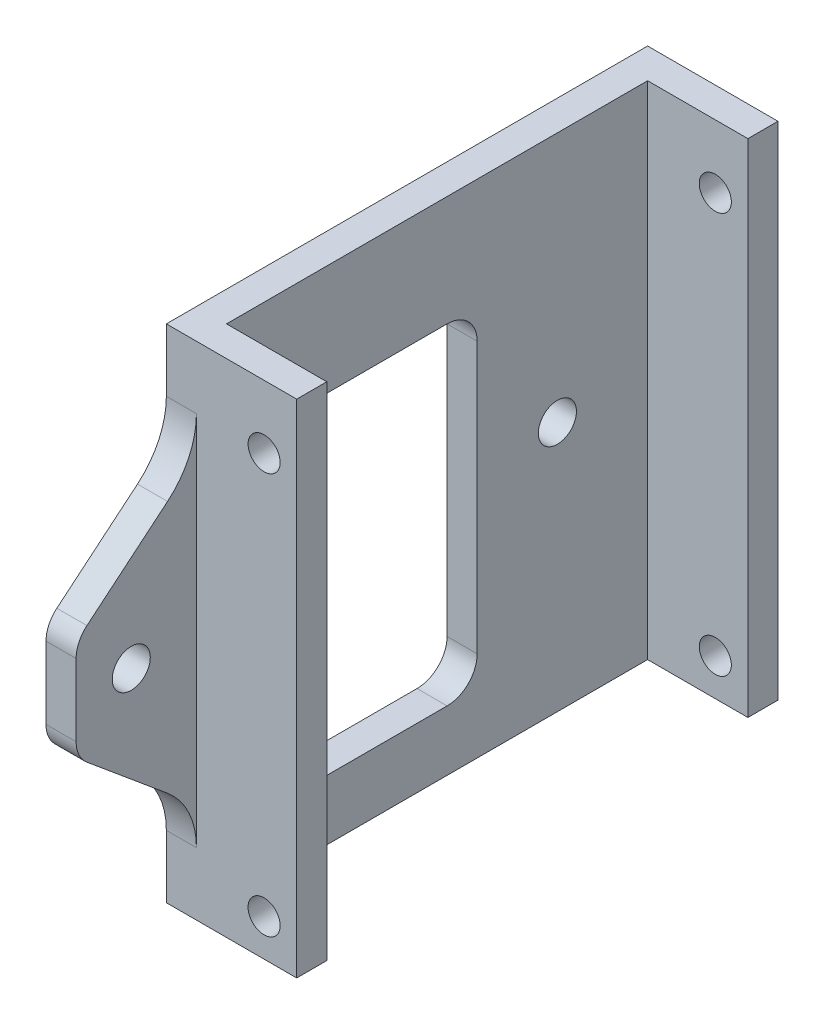
from build123d import *

# Parameters (mm, degrees)
BOSS_EXTRUDE1_DEPTH   = 50
SKETCH3_R             = 1.6
CUT_EXTRUDE1_DEPTH    = 49
SKETCH4_W             = 23.4
SKETCH4_H             = 33
CUT_EXTRUDE2_DEPTH    = 4
FILLET1_R             = 3
FILLET2_R             = 3
F_6_CLEARANCE_HOLE1_D = 3.7973


with BuildPart() as part:
    # Sketch1 → Boss-Extrude1 (new body)
    with BuildSketch(Plane(origin=(0, 0, 0), x_dir=(1, 0, 0), z_dir=(0, 1, 0))):
        Polygon((0, 0), (0, 48), (3, 48), (13, 48), (13, 45), (3, 45), (3, 3), (13, 3), (13, 0), (3, 0), (3, -12), (0, -12), align=None)
    extrude(amount=BOSS_EXTRUDE1_DEPTH)

    # Sketch3 → Cut-Extrude1 (cut, through all)
    with BuildSketch(Plane.XY):
        with Locations((9.75, 43.7)):
            Circle(SKETCH3_R)
        with Locations((9.75, 3.7)):
            Circle(SKETCH3_R)
    extrude(amount=-CUT_EXTRUDE1_DEPTH, mode=Mode.SUBTRACT)

    # Sketch4 → Cut-Extrude2 (cut, through all)
    with BuildSketch(Plane(origin=(3, 0, 0), x_dir=(0, 0, -1), z_dir=(1, 0, 0))):
        with BuildLine():
            Line((0, 50), (-12, 50))
            Line((-12, 50), (-12, 30))
            Line((-12, 30), (-2.878524803, 37.601229331))
            ThreePointArc((-2.878524803, 37.601229331), (-0.75528463, 40.353756398), (0, 43.746999568))
            Line((0, 43.746999568), (0, 50))
        make_face()
        with BuildLine():
            Line((0, 0), (0, 6.253000432))
            ThreePointArc((0, 6.253000432), (-0.75528463, 9.646243602), (-2.878524803, 12.398770669))
            Line((-2.878524803, 12.398770669), (-12, 20))
            Line((-12, 20), (-12, 0))
            Line((-12, 0), (0, 0))
        make_face()
        with Locations((16.3, 22.5)):
            Rectangle(SKETCH4_W, SKETCH4_H)
    extrude(amount=-CUT_EXTRUDE2_DEPTH, mode=Mode.SUBTRACT)

    # Fillet1
    fillet1_edges = [part.edges().sort_by_distance(p)[0] for p in [
        (1.5, 20, 12),
        (1.5, 30, 12),
    ]]
    fillet(fillet1_edges, radius=FILLET1_R)

    # Fillet2
    fillet2_edges = [part.edges().sort_by_distance(p)[0] for p in [
        (1.5, 6, -28),
        (1.5, 6, -4.6),
        (1.5, 39, -4.6),
        (1.5, 39, -28),
    ]]
    fillet(fillet2_edges, radius=FILLET2_R)

    # #6 Clearance Hole1 (through all)
    with Locations(Plane(origin=(3, 0, 0), x_dir=(0, 0, -1), z_dir=(1, 0, 0))):
        with Locations((-6.5, 25), (36, 25)):
            Hole(F_6_CLEARANCE_HOLE1_D / 2)


solid = part.part
